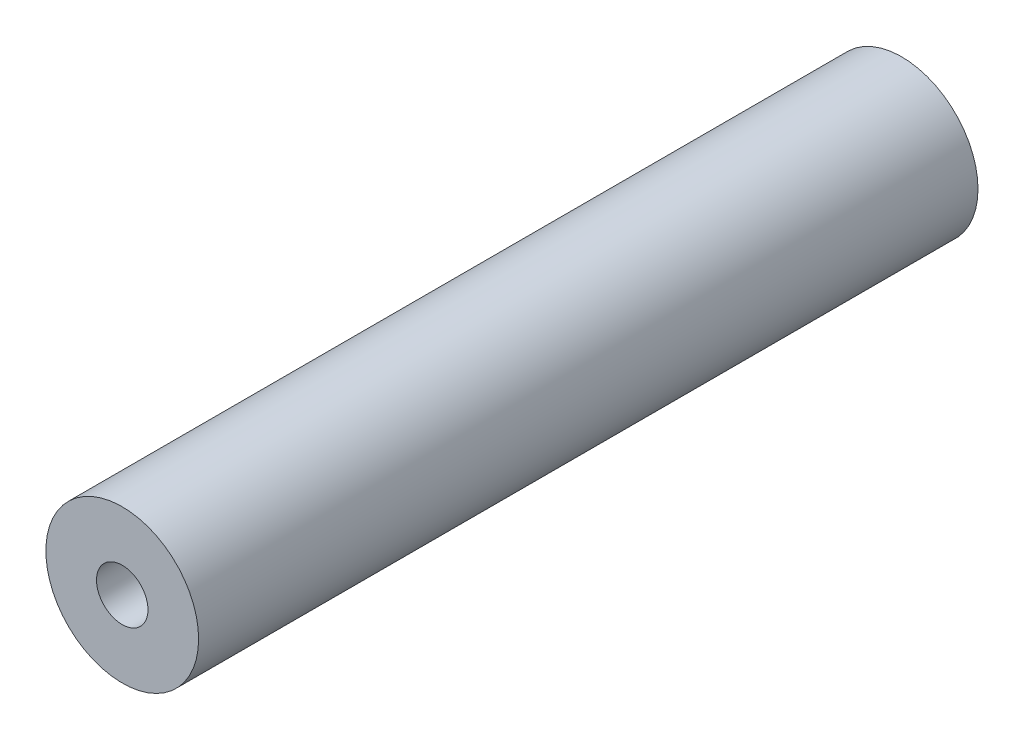
from build123d import *

# Parameters (mm, degrees)
SKETCH_1_R             = 4.9
EXTRUDE_1_DEPTH        = 50
HOLE_WIZARD_M4_1_D     = 3.3
HOLE_WIZARD_M4_1_DEPTH = 11.5
HOLE_WIZARD_M4_1_TIP   = 0.991420021
HOLE_WIZARD_M4_2_D     = 3.3
HOLE_WIZARD_M4_2_DEPTH = 11.5
HOLE_WIZARD_M4_2_TIP   = 0.991420021


with BuildPart() as part:
    # 스케치1 → 보스-돌출1 (new body)
    with BuildSketch(Plane.XY):
        Circle(SKETCH_1_R)
    extrude(amount=EXTRUDE_1_DEPTH)

    # M4 나사 구멍1
    with Locations(Plane.XY.offset(50)):
        with Locations((0, 0)):
            Hole(HOLE_WIZARD_M4_1_D / 2, depth=HOLE_WIZARD_M4_1_DEPTH)
            with Locations((0, 0, -(HOLE_WIZARD_M4_1_DEPTH + HOLE_WIZARD_M4_1_TIP / 2))):  # 118° drill point
                Cone(0, HOLE_WIZARD_M4_1_D / 2, HOLE_WIZARD_M4_1_TIP, mode=Mode.SUBTRACT)

    # M4 나사 구멍2
    with Locations(Plane(origin=(0, 0, 0), x_dir=(-1, 0, 0), z_dir=(0, 0, -1))):
        with Locations((0, 0)):
            Hole(HOLE_WIZARD_M4_2_D / 2, depth=HOLE_WIZARD_M4_2_DEPTH)
            with Locations((0, 0, -(HOLE_WIZARD_M4_2_DEPTH + HOLE_WIZARD_M4_2_TIP / 2))):  # 118° drill point
                Cone(0, HOLE_WIZARD_M4_2_D / 2, HOLE_WIZARD_M4_2_TIP, mode=Mode.SUBTRACT)


solid = part.part
